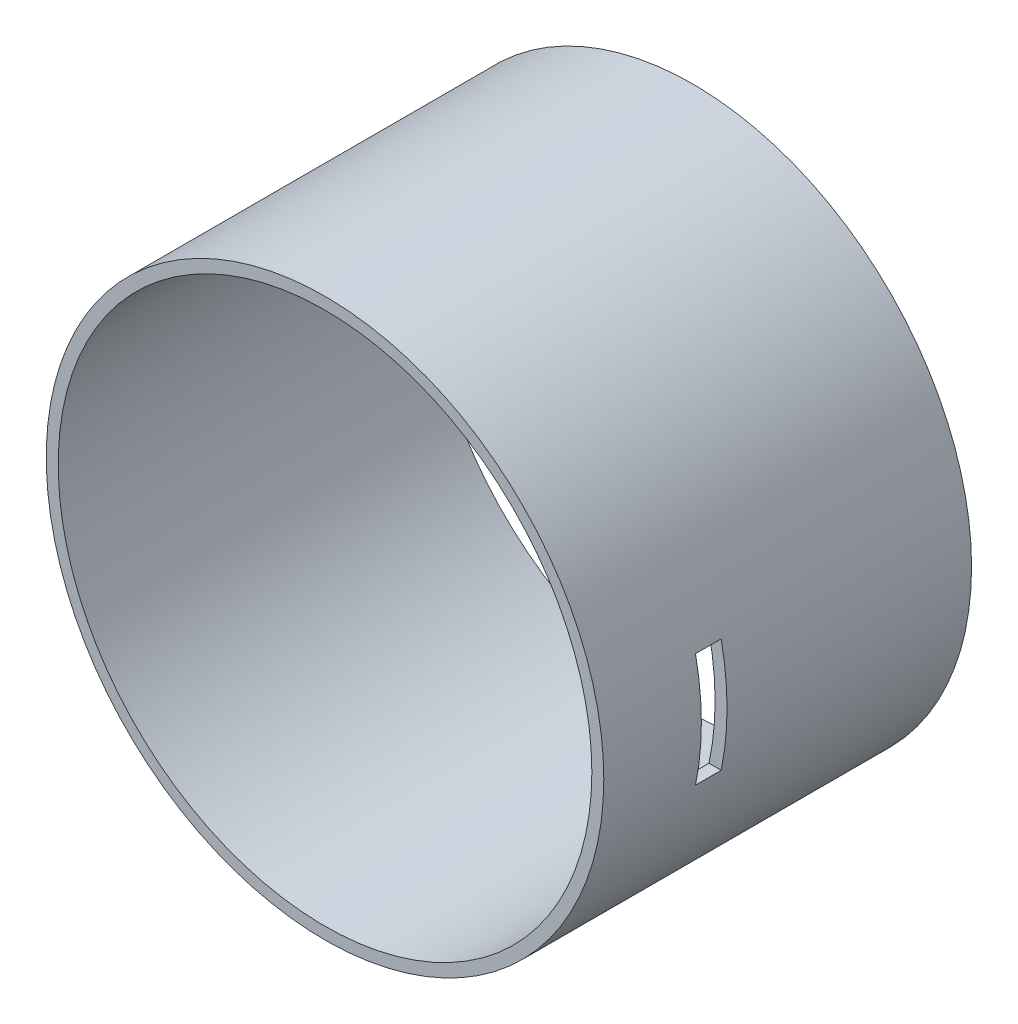
from build123d import *

# Parameters (mm, degrees)
SKETCH1_R                 = 140
SKETCH1_R_2               = 134
BOSS_EXTRUDE1_DEPTH       = 184.7
M2X0_4_TAPPED_HOLE2_D     = 1.6
M2X0_4_TAPPED_HOLE2_DEPTH = 3.6
M2X0_4_TAPPED_HOLE2_TIP   = 0.480688495
SKETCH5_W                 = 12.9
SKETCH5_H                 = 57.15
CUT_EXTRUDE1_DEPTH        = 140


with BuildPart() as part:
    # Sketch1 → Boss-Extrude1 (new body)
    with BuildSketch(Plane.XY):
        Circle(SKETCH1_R)
        Circle(SKETCH1_R_2, mode=Mode.SUBTRACT)
    extrude(amount=BOSS_EXTRUDE1_DEPTH)

    # M2x0.4 Tapped Hole2
    with Locations(Plane(origin=(0, 0, 0), x_dir=(-1, 0, 0), z_dir=(0, 0, -1))):
        with Locations((0, 137), (137, 0), (93.955376533, 99.116205732), (96.874, -96.874), (0, -137), (-96.874, -96.874), (-137, 0), (-96.874, 96.874)):
            Hole(M2X0_4_TAPPED_HOLE2_D / 2, depth=M2X0_4_TAPPED_HOLE2_DEPTH)
            with Locations((0, 0, -(M2X0_4_TAPPED_HOLE2_DEPTH + M2X0_4_TAPPED_HOLE2_TIP / 2))):  # 118° drill point
                Cone(0, M2X0_4_TAPPED_HOLE2_D / 2, M2X0_4_TAPPED_HOLE2_TIP, mode=Mode.SUBTRACT)

    # Sketch5 → Cut-Extrude1 (cut)
    with BuildSketch(Plane(origin=(0, 0, 0), x_dir=(0, 0, -1), z_dir=(1, 0, 0))):
        with Locations((-129.25, 0)):
            Rectangle(SKETCH5_W, SKETCH5_H)
    extrude(amount=CUT_EXTRUDE1_DEPTH, mode=Mode.SUBTRACT)


solid = part.part
